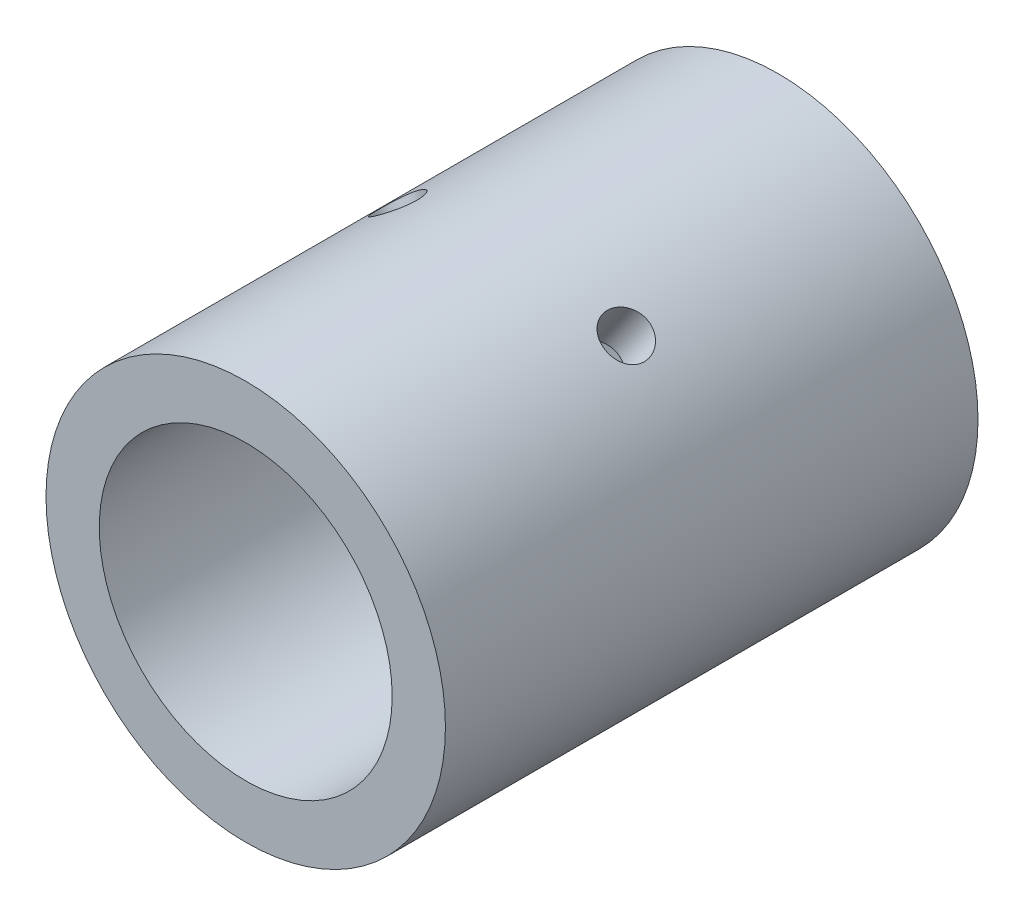
from build123d import *

# Parameters (mm, degrees)
SKICA1_R                    = 37.5
SKICA1_R_2                  = 27.5
VYSUNOUT_TENKOST_NN_1_DEPTH = 50
M10_Z_VIT1_D                = 8.5
M10_Z_VIT1_DEPTH            = 27.5
M10_Z_VIT1_TIP              = 2.553657631
M10_Z_VIT1_ON_FACE_2_D      = 8.5
M10_Z_VIT1_ON_FACE_2_DEPTH  = 27.5
M10_Z_VIT1_ON_FACE_2_TIP    = 2.553657631


with BuildPart() as part:
    # Skica1 → Vysunout tenkostěnný1 (new body, symmetric)
    with BuildSketch(Plane.XY):
        Circle(SKICA1_R)
        Circle(SKICA1_R_2, mode=Mode.SUBTRACT)
    extrude(amount=VYSUNOUT_TENKOST_NN_1_DEPTH, both=True)

    # M10 závit1
    with Locations(Plane(origin=(-21.509116363, 30.718201661, 0), x_dir=(0.819152044, 0.573576436, 0), z_dir=(-0.573576436, 0.819152044, 0))):
        with Locations((0, 0)):
            Hole(M10_Z_VIT1_D / 2, depth=M10_Z_VIT1_DEPTH)
            with Locations((0, 0, -(M10_Z_VIT1_DEPTH + M10_Z_VIT1_TIP / 2))):  # 118° drill point
                Cone(0, M10_Z_VIT1_D / 2, M10_Z_VIT1_TIP, mode=Mode.SUBTRACT)

    # M10 závit1 on face 2
    with Locations(Plane(origin=(21.509116363, 30.718201661, 0), x_dir=(0.819152235, -0.573576164, 0), z_dir=(0.573576164, 0.819152235, 0))):
        with Locations((0, 0)):
            Hole(M10_Z_VIT1_ON_FACE_2_D / 2, depth=M10_Z_VIT1_ON_FACE_2_DEPTH)
            with Locations((0, 0, -(M10_Z_VIT1_ON_FACE_2_DEPTH + M10_Z_VIT1_ON_FACE_2_TIP / 2))):  # 118° drill point
                Cone(0, M10_Z_VIT1_ON_FACE_2_D / 2, M10_Z_VIT1_ON_FACE_2_TIP, mode=Mode.SUBTRACT)


solid = part.part
